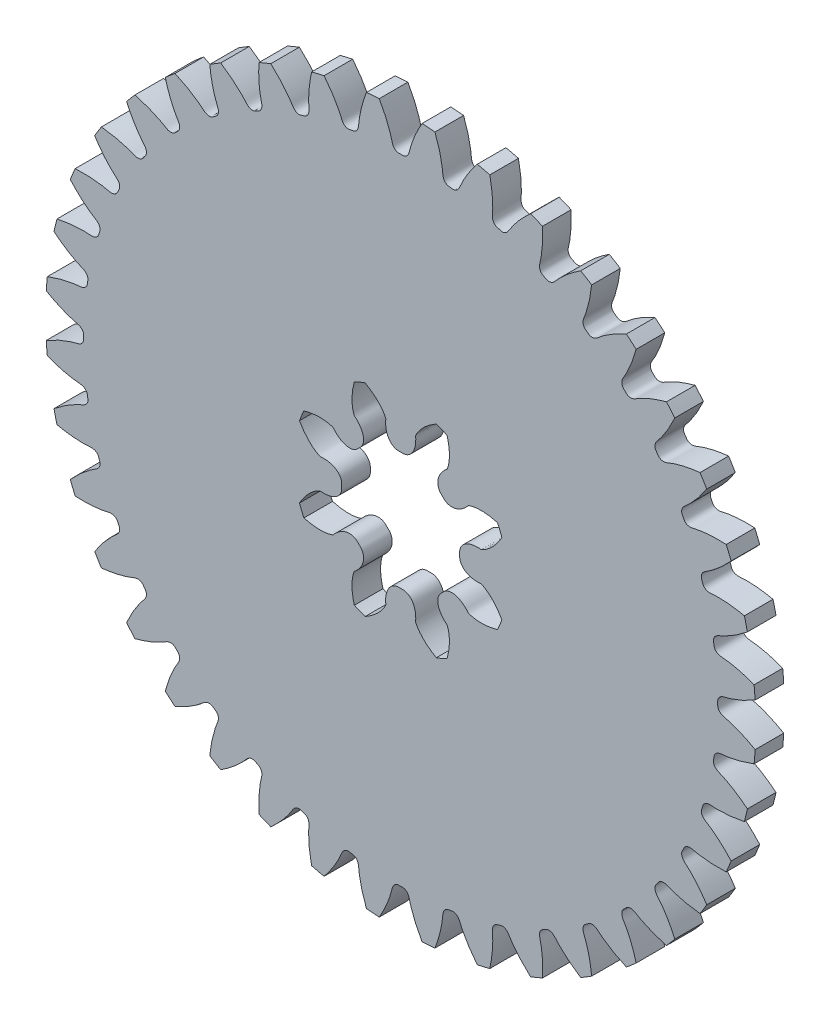
from build123d import *

# Parameters (mm, degrees)
SKETCHREVOLVESPUR03_W       = 0.250000008
SKETCHREVOLVESPUR03_H       = 3.102272727
TOOTHEXTRUDECUTSPUR03_DEPTH = 0.125000004
PATTERNSPUR03_COUNT         = 40
CORTAR_EXTRUIR1_REACH       = 2.25


with BuildPart() as part:
    # SketchRevolveSpur03 → Spur03 (revolve)
    with BuildSketch(Plane(origin=(0, 0, 0), x_dir=(0, 0, -1), z_dir=(1, 0, 0))):
        with Locations((0, 1.551136364)):
            Rectangle(SKETCHREVOLVESPUR03_W, SKETCHREVOLVESPUR03_H)
    revolve(axis=Axis((0, 0, 0), (0, 0, -1)))

    # SketchToothSpur03 → ToothExtrudeCutSpur03 (cut, symmetric)
    with BuildSketch(Plane.XY):
        with BuildLine():
            ThreePointArc((3.103756958, 0.191500414), (3.109659091, 0), (3.103756958, -0.191500414))
            add(Edge.make_bspline(
                [(3.103756958, -0.191500414), (3.089958571, -0.183437206), (3.069434937, -0.171909373), (3.042182547, -0.157559173), (3.022725887, -0.147750608), (3.003885393, -0.138667971), (2.985680448, -0.130286203), (2.968129739, -0.122579785), (2.951251244, -0.115522753), (2.935062223, -0.109088743), (2.919579222, -0.103250927), (2.904818003, -0.097982292), (2.890793757, -0.09325477), (2.877520332, -0.089042288), (2.865012831, -0.085310464), (2.853278786, -0.082051555), (2.840110694, -0.078576768), (2.829541976, -0.076303361), (2.821577551, -0.074080182), (2.81804308, -0.072981439), (2.814565605, -0.071785315), (2.811133562, -0.070477155), (2.807733196, -0.069039835), (2.804349374, -0.067450131), (2.800965801, -0.065677577), (2.797566051, -0.063682079), (2.794135555, -0.06141129), (2.790665342, -0.058797738), (2.787158476, -0.055756522), (2.783640387, -0.052185354), (2.780173538, -0.047970253), (2.77687517, -0.043002165), (2.773929219, -0.037209007), (2.7715863, -0.030604601), (2.770167189, -0.023647953), (2.76958925, -0.013359111), (2.770097963, 0), (2.76958925, 0.013359111), (2.770167189, 0.023647953), (2.7715863, 0.030604601), (2.773929219, 0.037209007), (2.77687517, 0.043002165), (2.780173538, 0.047970253), (2.783640387, 0.052185354), (2.787158476, 0.055756522), (2.790665342, 0.058797738), (2.794135555, 0.06141129), (2.797566051, 0.063682079), (2.800965801, 0.065677577), (2.804349374, 0.067450131), (2.807733196, 0.069039835), (2.811133562, 0.070477155), (2.814565605, 0.071785315), (2.81804308, 0.072981439), (2.821577551, 0.074080182), (2.829541976, 0.076303361), (2.840110694, 0.078576768), (2.853278786, 0.082051555), (2.865012831, 0.085310464), (2.877520332, 0.089042288), (2.890793757, 0.09325477), (2.904818003, 0.097982292), (2.919579222, 0.103250927), (2.935062223, 0.109088743), (2.951251244, 0.115522753), (2.968129739, 0.122579785), (2.985680448, 0.130286203), (3.003885393, 0.138667971), (3.022725887, 0.147750608), (3.042182547, 0.157559173), (3.069434937, 0.171909373), (3.089958571, 0.183437206), (3.103756958, 0.191500414)],
                knots=[0, 0, 0, 0, 0.058939817, 0.086798701, 0.113583569, 0.139294421, 0.163931256, 0.187494075, 0.209982877, 0.231397663, 0.251738433, 0.271005186, 0.289197923, 0.306316644, 0.322361348, 0.337332036, 0.351228708, 0.37258347, 0.377176766, 0.381719791, 0.386232054, 0.390736985, 0.395262836, 0.399843783, 0.404521226, 0.409345251, 0.414376113, 0.419685382, 0.425356036, 0.431480139, 0.438151913, 0.445453321, 0.453430002, 0.462059599, 0.471223406, 0.479505771, 0.5, 0.520494229, 0.528776594, 0.537940401, 0.546569998, 0.554546679, 0.561848087, 0.568519861, 0.574643964, 0.580314618, 0.585623887, 0.590654749, 0.595478774, 0.600156217, 0.604737164, 0.609263015, 0.613767946, 0.618280209, 0.622823234, 0.62741653, 0.648771292, 0.662667964, 0.677638652, 0.693683356, 0.710802077, 0.728994814, 0.748261567, 0.768602337, 0.790017123, 0.812505925, 0.836068744, 0.860705579, 0.886416431, 0.913201299, 0.941060183, 1, 1, 1, 1], degree=3))
        make_face()
    toothextrudecutspur03 = extrude(amount=TOOTHEXTRUDECUTSPUR03_DEPTH, both=True, mode=Mode.SUBTRACT)

    # PatternSpur03: ToothExtrudeCutSpur03 ×40 about axis
    patternspur03_axis = Axis((0, 0, 55), (0, 0, -1))
    for i in range(1, PATTERNSPUR03_COUNT):
        add(toothextrudecutspur03.rotate(patternspur03_axis, i * 360 / PATTERNSPUR03_COUNT), mode=Mode.SUBTRACT)

    # Croquis1 → Cortar-Extruir1 (cut, up to next)
    with BuildSketch(Plane.XY.offset(0.125000004), mode=Mode.PRIVATE) as cortar_extruir1_sk1:
        with BuildLine():
            ThreePointArc((0.884276826, 0.311385204), (0.866137062, 0.358765718), (0.845460729, 0.40509555))
            add(Edge.make_bspline(
                [(0.40509555, 0.845460729), (0.41104992, 0.82421079), (0.417581278, 0.795017734), (0.422660577, 0.758165224), (0.424683928, 0.736267056), (0.425657177, 0.715717392), (0.425705504, 0.696563518), (0.424955758, 0.678844441), (0.423537683, 0.662589442), (0.421577298, 0.647822948), (0.419216329, 0.63454842), (0.416547699, 0.622799977), (0.41381674, 0.612479723), (0.409996653, 0.601570817), (0.406537284, 0.587402055), (0.393839297, 0.580181147), (0.385745612, 0.571960162), (0.379502767, 0.565796374), (0.37365305, 0.559490513), (0.368090946, 0.553127716), (0.362844752, 0.546690764), (0.357908152, 0.540188436), (0.353284269, 0.53362198), (0.348974315, 0.526993814), (0.344980743, 0.520305215), (0.341306635, 0.513556897), (0.337956124, 0.506748868), (0.334934586, 0.499880513), (0.332248947, 0.492950674), (0.329908003, 0.485957822), (0.327922789, 0.47890031), (0.326306957, 0.471776771), (0.325077161, 0.464586672), (0.324253388, 0.457331077), (0.323859178, 0.450013663), (0.323921634, 0.442641992), (0.324471102, 0.435229056), (0.325540351, 0.427795002), (0.327163143, 0.42036895), (0.329371904, 0.41299049), (0.332195098, 0.405711082), (0.335652038, 0.398592737), (0.339754663, 0.391711891), (0.344482093, 0.385136545), (0.349178399, 0.379775699), (0.355871813, 0.372902772), (0.364763468, 0.364763468), (0.372902772, 0.355871813), (0.379775699, 0.349178399), (0.385136545, 0.344482093), (0.391711891, 0.339754663), (0.398592737, 0.335652038), (0.405711082, 0.332195098), (0.41299049, 0.329371904), (0.42036895, 0.327163143), (0.427795002, 0.325540351), (0.435229056, 0.324471102), (0.442641992, 0.323921634), (0.450013663, 0.323859178), (0.457331077, 0.324253388), (0.464586672, 0.325077161), (0.471776771, 0.326306957), (0.47890031, 0.327922789), (0.485957822, 0.329908003), (0.492950674, 0.332248947), (0.499880513, 0.334934586), (0.506748868, 0.337956124), (0.513556897, 0.341306635), (0.520305215, 0.344980743), (0.526993814, 0.348974315), (0.53362198, 0.353284269), (0.540188436, 0.357908152), (0.546690764, 0.362844752), (0.553127716, 0.368090946), (0.559490513, 0.37365305), (0.565796374, 0.379502767), (0.571960162, 0.385745612), (0.580181147, 0.393839297), (0.587402055, 0.406537284), (0.601570817, 0.409996653), (0.612479723, 0.41381674), (0.622799977, 0.416547699), (0.63454842, 0.419216329), (0.647822948, 0.421577298), (0.662589442, 0.423537683), (0.678844441, 0.424955758), (0.696563518, 0.425705504), (0.715717392, 0.425657177), (0.736267056, 0.424683928), (0.758165224, 0.422660577), (0.795017734, 0.417581278), (0.82421079, 0.41104992), (0.845460729, 0.40509555)],
                knots=[0.011652886, 0.011652886, 0.011652886, 0.011652886, 0.073215091, 0.094985485, 0.115436462, 0.13456802, 0.152380161, 0.168872885, 0.18404619, 0.197900078, 0.210434548, 0.2216496, 0.231545235, 0.240121452, 0.254210701, 0.270122213, 0.278421846, 0.286569565, 0.29456997, 0.302428107, 0.310149525, 0.317740329, 0.325207234, 0.332557632, 0.339799658, 0.346942256, 0.353995249, 0.360969402, 0.367876475, 0.374729261, 0.381541598, 0.388328329, 0.395105215, 0.40188875, 0.408695881, 0.415543575, 0.422448236, 0.429424941, 0.436486513, 0.443642464, 0.450897926, 0.458252678, 0.465700501, 0.473229037, 0.480820311, 0.485565802, 0.5, 0.514434198, 0.519179689, 0.526770963, 0.534299499, 0.541747322, 0.549102074, 0.556357536, 0.563513487, 0.570575059, 0.577551764, 0.584456425, 0.591304119, 0.59811125, 0.604894785, 0.611671671, 0.618458402, 0.625270739, 0.632123525, 0.639030598, 0.646004751, 0.653057744, 0.660200342, 0.667442368, 0.674792766, 0.682259671, 0.689850475, 0.697571893, 0.70543003, 0.713430435, 0.721578154, 0.729877787, 0.745789299, 0.759878548, 0.768454765, 0.7783504, 0.789565452, 0.802099922, 0.81595381, 0.831127115, 0.847619839, 0.86543198, 0.884563538, 0.905014515, 0.926784909, 0.988347114, 0.988347114, 0.988347114, 0.988347114], degree=3))
            ThreePointArc((0.40509555, 0.845460729), (0.358765718, 0.866137062), (0.311385204, 0.884276826))
            add(Edge.make_bspline(
                [(-0.311385204, 0.884276826), (-0.292148853, 0.873461225), (-0.266887878, 0.857436984), (-0.237237611, 0.834969931), (-0.220322543, 0.820916314), (-0.205103545, 0.807073697), (-0.191525539, 0.793564035), (-0.179526409, 0.780504605), (-0.169035119, 0.768007855), (-0.159979833, 0.756180166), (-0.152262782, 0.7451242), (-0.145842384, 0.73492979), (-0.140475942, 0.725701189), (-0.13546339, 0.715286218), (-0.127890706, 0.702821246), (-0.131763586, 0.688736461), (-0.131673571, 0.677200247), (-0.131729473, 0.668427432), (-0.131406931, 0.659832141), (-0.130840755, 0.651399963), (-0.129998762, 0.643138731), (-0.128891624, 0.635050187), (-0.127518019, 0.627137423), (-0.125878795, 0.619403004), (-0.123973123, 0.611849568), (-0.121799328, 0.6044798), (-0.119354494, 0.597296628), (-0.116634383, 0.590303417), (-0.113633281, 0.583504248), (-0.110343885, 0.576904257), (-0.106757229, 0.570510084), (-0.102862692, 0.564330416), (-0.098648121, 0.558376651), (-0.094100136, 0.552663676), (-0.089204692, 0.547210734), (-0.08394797, 0.542042338), (-0.0783177, 0.537189134), (-0.072304957, 0.532688537), (-0.065906458, 0.528585012), (-0.059127269, 0.524929483), (-0.051983651, 0.521778464), (-0.044505795, 0.51918946), (-0.036739308, 0.517224961), (-0.028747039, 0.515918287), (-0.021635558, 0.515448385), (-0.012042707, 0.515321452), (0, 0.515853444), (0.012042707, 0.515321452), (0.021635558, 0.515448385), (0.028747039, 0.515918287), (0.036739308, 0.517224961), (0.044505795, 0.51918946), (0.051983651, 0.521778464), (0.059127269, 0.524929483), (0.065906458, 0.528585012), (0.072304957, 0.532688537), (0.0783177, 0.537189134), (0.08394797, 0.542042338), (0.089204692, 0.547210734), (0.094100136, 0.552663676), (0.098648121, 0.558376651), (0.102862692, 0.564330416), (0.106757229, 0.570510084), (0.110343885, 0.576904257), (0.113633281, 0.583504248), (0.116634383, 0.590303417), (0.119354494, 0.597296628), (0.121799328, 0.6044798), (0.123973123, 0.611849568), (0.125878795, 0.619403004), (0.127518019, 0.627137423), (0.128891624, 0.635050187), (0.129998762, 0.643138731), (0.130840755, 0.651399963), (0.131406931, 0.659832141), (0.131729473, 0.668427432), (0.131673571, 0.677200247), (0.131763586, 0.688736461), (0.127890706, 0.702821246), (0.13546339, 0.715286218), (0.140475942, 0.725701189), (0.145842384, 0.73492979), (0.152262782, 0.7451242), (0.159979833, 0.756180166), (0.169035119, 0.768007855), (0.179526409, 0.780504605), (0.191525539, 0.793564035), (0.205103545, 0.807073697), (0.220322543, 0.820916314), (0.237237611, 0.834969931), (0.266887878, 0.857436984), (0.292148853, 0.873461225), (0.311385204, 0.884276826)],
                knots=[0.011652886, 0.011652886, 0.011652886, 0.011652886, 0.073215091, 0.094985485, 0.115436462, 0.13456802, 0.152380161, 0.168872885, 0.18404619, 0.197900078, 0.210434548, 0.2216496, 0.231545235, 0.240121452, 0.254210701, 0.270122213, 0.278421846, 0.286569565, 0.29456997, 0.302428107, 0.310149525, 0.317740329, 0.325207234, 0.332557632, 0.339799658, 0.346942256, 0.353995249, 0.360969402, 0.367876475, 0.374729261, 0.381541598, 0.388328329, 0.395105215, 0.40188875, 0.408695881, 0.415543575, 0.422448236, 0.429424941, 0.436486513, 0.443642464, 0.450897926, 0.458252678, 0.465700501, 0.473229037, 0.480820311, 0.485565802, 0.5, 0.514434198, 0.519179689, 0.526770963, 0.534299499, 0.541747322, 0.549102074, 0.556357536, 0.563513487, 0.570575059, 0.577551764, 0.584456425, 0.591304119, 0.59811125, 0.604894785, 0.611671671, 0.618458402, 0.625270739, 0.632123525, 0.639030598, 0.646004751, 0.653057744, 0.660200342, 0.667442368, 0.674792766, 0.682259671, 0.689850475, 0.697571893, 0.70543003, 0.713430435, 0.721578154, 0.729877787, 0.745789299, 0.759878548, 0.768454765, 0.7783504, 0.789565452, 0.802099922, 0.81595381, 0.831127115, 0.847619839, 0.86543198, 0.884563538, 0.905014515, 0.926784909, 0.988347114, 0.988347114, 0.988347114, 0.988347114], degree=3))
            ThreePointArc((-0.311385204, 0.884276826), (-0.358765718, 0.866137062), (-0.40509555, 0.845460729))
            add(Edge.make_bspline(
                [(-0.845460729, 0.40509555), (-0.82421079, 0.41104992), (-0.795017734, 0.417581278), (-0.758165224, 0.422660577), (-0.736267056, 0.424683928), (-0.715717392, 0.425657177), (-0.696563518, 0.425705504), (-0.678844441, 0.424955758), (-0.662589442, 0.423537683), (-0.647822948, 0.421577298), (-0.63454842, 0.419216329), (-0.622799977, 0.416547699), (-0.612479723, 0.41381674), (-0.601570817, 0.409996653), (-0.587402055, 0.406537284), (-0.580181147, 0.393839297), (-0.571960162, 0.385745612), (-0.565796374, 0.379502767), (-0.559490513, 0.37365305), (-0.553127716, 0.368090946), (-0.546690764, 0.362844752), (-0.540188436, 0.357908152), (-0.53362198, 0.353284269), (-0.526993814, 0.348974315), (-0.520305215, 0.344980743), (-0.513556897, 0.341306635), (-0.506748868, 0.337956124), (-0.499880513, 0.334934586), (-0.492950674, 0.332248947), (-0.485957822, 0.329908003), (-0.47890031, 0.327922789), (-0.471776771, 0.326306957), (-0.464586672, 0.325077161), (-0.457331077, 0.324253388), (-0.450013663, 0.323859178), (-0.442641992, 0.323921634), (-0.435229056, 0.324471102), (-0.427795002, 0.325540351), (-0.42036895, 0.327163143), (-0.41299049, 0.329371904), (-0.405711082, 0.332195098), (-0.398592737, 0.335652038), (-0.391711891, 0.339754663), (-0.385136545, 0.344482093), (-0.379775699, 0.349178399), (-0.372902772, 0.355871813), (-0.364763468, 0.364763468), (-0.355871813, 0.372902772), (-0.349178399, 0.379775699), (-0.344482093, 0.385136545), (-0.339754663, 0.391711891), (-0.335652038, 0.398592737), (-0.332195098, 0.405711082), (-0.329371904, 0.41299049), (-0.327163143, 0.42036895), (-0.325540351, 0.427795002), (-0.324471102, 0.435229056), (-0.323921634, 0.442641992), (-0.323859178, 0.450013663), (-0.324253388, 0.457331077), (-0.325077161, 0.464586672), (-0.326306957, 0.471776771), (-0.327922789, 0.47890031), (-0.329908003, 0.485957822), (-0.332248947, 0.492950674), (-0.334934586, 0.499880513), (-0.337956124, 0.506748868), (-0.341306635, 0.513556897), (-0.344980743, 0.520305215), (-0.348974315, 0.526993814), (-0.353284269, 0.53362198), (-0.357908152, 0.540188436), (-0.362844752, 0.546690764), (-0.368090946, 0.553127716), (-0.37365305, 0.559490513), (-0.379502767, 0.565796374), (-0.385745612, 0.571960162), (-0.393839297, 0.580181147), (-0.406537284, 0.587402055), (-0.409996653, 0.601570817), (-0.41381674, 0.612479723), (-0.416547699, 0.622799977), (-0.419216329, 0.63454842), (-0.421577298, 0.647822948), (-0.423537683, 0.662589442), (-0.424955758, 0.678844441), (-0.425705504, 0.696563518), (-0.425657177, 0.715717392), (-0.424683928, 0.736267056), (-0.422660577, 0.758165224), (-0.417581278, 0.795017734), (-0.41104992, 0.82421079), (-0.40509555, 0.845460729)],
                knots=[0.011652886, 0.011652886, 0.011652886, 0.011652886, 0.073215091, 0.094985485, 0.115436462, 0.13456802, 0.152380161, 0.168872885, 0.18404619, 0.197900078, 0.210434548, 0.2216496, 0.231545235, 0.240121452, 0.254210701, 0.270122213, 0.278421846, 0.286569565, 0.29456997, 0.302428107, 0.310149525, 0.317740329, 0.325207234, 0.332557632, 0.339799658, 0.346942256, 0.353995249, 0.360969402, 0.367876475, 0.374729261, 0.381541598, 0.388328329, 0.395105215, 0.40188875, 0.408695881, 0.415543575, 0.422448236, 0.429424941, 0.436486513, 0.443642464, 0.450897926, 0.458252678, 0.465700501, 0.473229037, 0.480820311, 0.485565802, 0.5, 0.514434198, 0.519179689, 0.526770963, 0.534299499, 0.541747322, 0.549102074, 0.556357536, 0.563513487, 0.570575059, 0.577551764, 0.584456425, 0.591304119, 0.59811125, 0.604894785, 0.611671671, 0.618458402, 0.625270739, 0.632123525, 0.639030598, 0.646004751, 0.653057744, 0.660200342, 0.667442368, 0.674792766, 0.682259671, 0.689850475, 0.697571893, 0.70543003, 0.713430435, 0.721578154, 0.729877787, 0.745789299, 0.759878548, 0.768454765, 0.7783504, 0.789565452, 0.802099922, 0.81595381, 0.831127115, 0.847619839, 0.86543198, 0.884563538, 0.905014515, 0.926784909, 0.988347114, 0.988347114, 0.988347114, 0.988347114], degree=3))
            ThreePointArc((-0.845460729, 0.40509555), (-0.866137062, 0.358765718), (-0.884276826, 0.311385204))
            add(Edge.make_bspline(
                [(-0.884276826, -0.311385204), (-0.873461225, -0.292148853), (-0.857436984, -0.266887878), (-0.834969931, -0.237237611), (-0.820916314, -0.220322543), (-0.807073697, -0.205103545), (-0.793564035, -0.191525539), (-0.780504605, -0.179526409), (-0.768007855, -0.169035119), (-0.756180166, -0.159979833), (-0.7451242, -0.152262782), (-0.73492979, -0.145842384), (-0.725701189, -0.140475942), (-0.715286218, -0.13546339), (-0.702821246, -0.127890706), (-0.688736461, -0.131763586), (-0.677200247, -0.131673571), (-0.668427432, -0.131729473), (-0.659832141, -0.131406931), (-0.651399963, -0.130840755), (-0.643138731, -0.129998762), (-0.635050187, -0.128891624), (-0.627137423, -0.127518019), (-0.619403004, -0.125878795), (-0.611849568, -0.123973123), (-0.6044798, -0.121799328), (-0.597296628, -0.119354494), (-0.590303417, -0.116634383), (-0.583504248, -0.113633281), (-0.576904257, -0.110343885), (-0.570510084, -0.106757229), (-0.564330416, -0.102862692), (-0.558376651, -0.098648121), (-0.552663676, -0.094100136), (-0.547210734, -0.089204692), (-0.542042338, -0.08394797), (-0.537189134, -0.0783177), (-0.532688537, -0.072304957), (-0.528585012, -0.065906458), (-0.524929483, -0.059127269), (-0.521778464, -0.051983651), (-0.51918946, -0.044505795), (-0.517224961, -0.036739308), (-0.515918287, -0.028747039), (-0.515448385, -0.021635558), (-0.515321452, -0.012042707), (-0.515853444, 0), (-0.515321452, 0.012042707), (-0.515448385, 0.021635558), (-0.515918287, 0.028747039), (-0.517224961, 0.036739308), (-0.51918946, 0.044505795), (-0.521778464, 0.051983651), (-0.524929483, 0.059127269), (-0.528585012, 0.065906458), (-0.532688537, 0.072304957), (-0.537189134, 0.0783177), (-0.542042338, 0.08394797), (-0.547210734, 0.089204692), (-0.552663676, 0.094100136), (-0.558376651, 0.098648121), (-0.564330416, 0.102862692), (-0.570510084, 0.106757229), (-0.576904257, 0.110343885), (-0.583504248, 0.113633281), (-0.590303417, 0.116634383), (-0.597296628, 0.119354494), (-0.6044798, 0.121799328), (-0.611849568, 0.123973123), (-0.619403004, 0.125878795), (-0.627137423, 0.127518019), (-0.635050187, 0.128891624), (-0.643138731, 0.129998762), (-0.651399963, 0.130840755), (-0.659832141, 0.131406931), (-0.668427432, 0.131729473), (-0.677200247, 0.131673571), (-0.688736461, 0.131763586), (-0.702821246, 0.127890706), (-0.715286218, 0.13546339), (-0.725701189, 0.140475942), (-0.73492979, 0.145842384), (-0.7451242, 0.152262782), (-0.756180166, 0.159979833), (-0.768007855, 0.169035119), (-0.780504605, 0.179526409), (-0.793564035, 0.191525539), (-0.807073697, 0.205103545), (-0.820916314, 0.220322543), (-0.834969931, 0.237237611), (-0.857436984, 0.266887878), (-0.873461225, 0.292148853), (-0.884276826, 0.311385204)],
                knots=[0.011652886, 0.011652886, 0.011652886, 0.011652886, 0.073215091, 0.094985485, 0.115436462, 0.13456802, 0.152380161, 0.168872885, 0.18404619, 0.197900078, 0.210434548, 0.2216496, 0.231545235, 0.240121452, 0.254210701, 0.270122213, 0.278421846, 0.286569565, 0.29456997, 0.302428107, 0.310149525, 0.317740329, 0.325207234, 0.332557632, 0.339799658, 0.346942256, 0.353995249, 0.360969402, 0.367876475, 0.374729261, 0.381541598, 0.388328329, 0.395105215, 0.40188875, 0.408695881, 0.415543575, 0.422448236, 0.429424941, 0.436486513, 0.443642464, 0.450897926, 0.458252678, 0.465700501, 0.473229037, 0.480820311, 0.485565802, 0.5, 0.514434198, 0.519179689, 0.526770963, 0.534299499, 0.541747322, 0.549102074, 0.556357536, 0.563513487, 0.570575059, 0.577551764, 0.584456425, 0.591304119, 0.59811125, 0.604894785, 0.611671671, 0.618458402, 0.625270739, 0.632123525, 0.639030598, 0.646004751, 0.653057744, 0.660200342, 0.667442368, 0.674792766, 0.682259671, 0.689850475, 0.697571893, 0.70543003, 0.713430435, 0.721578154, 0.729877787, 0.745789299, 0.759878548, 0.768454765, 0.7783504, 0.789565452, 0.802099922, 0.81595381, 0.831127115, 0.847619839, 0.86543198, 0.884563538, 0.905014515, 0.926784909, 0.988347114, 0.988347114, 0.988347114, 0.988347114], degree=3))
            ThreePointArc((-0.884276826, -0.311385204), (-0.866137062, -0.358765718), (-0.845460729, -0.40509555))
            add(Edge.make_bspline(
                [(-0.40509555, -0.845460729), (-0.41104992, -0.82421079), (-0.417581278, -0.795017734), (-0.422660577, -0.758165224), (-0.424683928, -0.736267056), (-0.425657177, -0.715717392), (-0.425705504, -0.696563518), (-0.424955758, -0.678844441), (-0.423537683, -0.662589442), (-0.421577298, -0.647822948), (-0.419216329, -0.63454842), (-0.416547699, -0.622799977), (-0.41381674, -0.612479723), (-0.409996653, -0.601570817), (-0.406537284, -0.587402055), (-0.393839297, -0.580181147), (-0.385745612, -0.571960162), (-0.379502767, -0.565796374), (-0.37365305, -0.559490513), (-0.368090946, -0.553127716), (-0.362844752, -0.546690764), (-0.357908152, -0.540188436), (-0.353284269, -0.53362198), (-0.348974315, -0.526993814), (-0.344980743, -0.520305215), (-0.341306635, -0.513556897), (-0.337956124, -0.506748868), (-0.334934586, -0.499880513), (-0.332248947, -0.492950674), (-0.329908003, -0.485957822), (-0.327922789, -0.47890031), (-0.326306957, -0.471776771), (-0.325077161, -0.464586672), (-0.324253388, -0.457331077), (-0.323859178, -0.450013663), (-0.323921634, -0.442641992), (-0.324471102, -0.435229056), (-0.325540351, -0.427795002), (-0.327163143, -0.42036895), (-0.329371904, -0.41299049), (-0.332195098, -0.405711082), (-0.335652038, -0.398592737), (-0.339754663, -0.391711891), (-0.344482093, -0.385136545), (-0.349178399, -0.379775699), (-0.355871813, -0.372902772), (-0.364763468, -0.364763468), (-0.372902772, -0.355871813), (-0.379775699, -0.349178399), (-0.385136545, -0.344482093), (-0.391711891, -0.339754663), (-0.398592737, -0.335652038), (-0.405711082, -0.332195098), (-0.41299049, -0.329371904), (-0.42036895, -0.327163143), (-0.427795002, -0.325540351), (-0.435229056, -0.324471102), (-0.442641992, -0.323921634), (-0.450013663, -0.323859178), (-0.457331077, -0.324253388), (-0.464586672, -0.325077161), (-0.471776771, -0.326306957), (-0.47890031, -0.327922789), (-0.485957822, -0.329908003), (-0.492950674, -0.332248947), (-0.499880513, -0.334934586), (-0.506748868, -0.337956124), (-0.513556897, -0.341306635), (-0.520305215, -0.344980743), (-0.526993814, -0.348974315), (-0.53362198, -0.353284269), (-0.540188436, -0.357908152), (-0.546690764, -0.362844752), (-0.553127716, -0.368090946), (-0.559490513, -0.37365305), (-0.565796374, -0.379502767), (-0.571960162, -0.385745612), (-0.580181147, -0.393839297), (-0.587402055, -0.406537284), (-0.601570817, -0.409996653), (-0.612479723, -0.41381674), (-0.622799977, -0.416547699), (-0.63454842, -0.419216329), (-0.647822948, -0.421577298), (-0.662589442, -0.423537683), (-0.678844441, -0.424955758), (-0.696563518, -0.425705504), (-0.715717392, -0.425657177), (-0.736267056, -0.424683928), (-0.758165224, -0.422660577), (-0.795017734, -0.417581278), (-0.82421079, -0.41104992), (-0.845460729, -0.40509555)],
                knots=[0.011652886, 0.011652886, 0.011652886, 0.011652886, 0.073215091, 0.094985485, 0.115436462, 0.13456802, 0.152380161, 0.168872885, 0.18404619, 0.197900078, 0.210434548, 0.2216496, 0.231545235, 0.240121452, 0.254210701, 0.270122213, 0.278421846, 0.286569565, 0.29456997, 0.302428107, 0.310149525, 0.317740329, 0.325207234, 0.332557632, 0.339799658, 0.346942256, 0.353995249, 0.360969402, 0.367876475, 0.374729261, 0.381541598, 0.388328329, 0.395105215, 0.40188875, 0.408695881, 0.415543575, 0.422448236, 0.429424941, 0.436486513, 0.443642464, 0.450897926, 0.458252678, 0.465700501, 0.473229037, 0.480820311, 0.485565802, 0.5, 0.514434198, 0.519179689, 0.526770963, 0.534299499, 0.541747322, 0.549102074, 0.556357536, 0.563513487, 0.570575059, 0.577551764, 0.584456425, 0.591304119, 0.59811125, 0.604894785, 0.611671671, 0.618458402, 0.625270739, 0.632123525, 0.639030598, 0.646004751, 0.653057744, 0.660200342, 0.667442368, 0.674792766, 0.682259671, 0.689850475, 0.697571893, 0.70543003, 0.713430435, 0.721578154, 0.729877787, 0.745789299, 0.759878548, 0.768454765, 0.7783504, 0.789565452, 0.802099922, 0.81595381, 0.831127115, 0.847619839, 0.86543198, 0.884563538, 0.905014515, 0.926784909, 0.988347114, 0.988347114, 0.988347114, 0.988347114], degree=3))
            ThreePointArc((-0.40509555, -0.845460729), (-0.358765718, -0.866137062), (-0.311385204, -0.884276826))
            add(Edge.make_bspline(
                [(0.311385204, -0.884276826), (0.292148853, -0.873461225), (0.266887878, -0.857436984), (0.237237611, -0.834969931), (0.220322543, -0.820916314), (0.205103545, -0.807073697), (0.191525539, -0.793564035), (0.179526409, -0.780504605), (0.169035119, -0.768007855), (0.159979833, -0.756180166), (0.152262782, -0.7451242), (0.145842384, -0.73492979), (0.140475942, -0.725701189), (0.13546339, -0.715286218), (0.127890706, -0.702821246), (0.131763586, -0.688736461), (0.131673571, -0.677200247), (0.131729473, -0.668427432), (0.131406931, -0.659832141), (0.130840755, -0.651399963), (0.129998762, -0.643138731), (0.128891624, -0.635050187), (0.127518019, -0.627137423), (0.125878795, -0.619403004), (0.123973123, -0.611849568), (0.121799328, -0.6044798), (0.119354494, -0.597296628), (0.116634383, -0.590303417), (0.113633281, -0.583504248), (0.110343885, -0.576904257), (0.106757229, -0.570510084), (0.102862692, -0.564330416), (0.098648121, -0.558376651), (0.094100136, -0.552663676), (0.089204692, -0.547210734), (0.08394797, -0.542042338), (0.0783177, -0.537189134), (0.072304957, -0.532688537), (0.065906458, -0.528585012), (0.059127269, -0.524929483), (0.051983651, -0.521778464), (0.044505795, -0.51918946), (0.036739308, -0.517224961), (0.028747039, -0.515918287), (0.021635558, -0.515448385), (0.012042707, -0.515321452), (0, -0.515853444), (-0.012042707, -0.515321452), (-0.021635558, -0.515448385), (-0.028747039, -0.515918287), (-0.036739308, -0.517224961), (-0.044505795, -0.51918946), (-0.051983651, -0.521778464), (-0.059127269, -0.524929483), (-0.065906458, -0.528585012), (-0.072304957, -0.532688537), (-0.0783177, -0.537189134), (-0.08394797, -0.542042338), (-0.089204692, -0.547210734), (-0.094100136, -0.552663676), (-0.098648121, -0.558376651), (-0.102862692, -0.564330416), (-0.106757229, -0.570510084), (-0.110343885, -0.576904257), (-0.113633281, -0.583504248), (-0.116634383, -0.590303417), (-0.119354494, -0.597296628), (-0.121799328, -0.6044798), (-0.123973123, -0.611849568), (-0.125878795, -0.619403004), (-0.127518019, -0.627137423), (-0.128891624, -0.635050187), (-0.129998762, -0.643138731), (-0.130840755, -0.651399963), (-0.131406931, -0.659832141), (-0.131729473, -0.668427432), (-0.131673571, -0.677200247), (-0.131763586, -0.688736461), (-0.127890706, -0.702821246), (-0.13546339, -0.715286218), (-0.140475942, -0.725701189), (-0.145842384, -0.73492979), (-0.152262782, -0.7451242), (-0.159979833, -0.756180166), (-0.169035119, -0.768007855), (-0.179526409, -0.780504605), (-0.191525539, -0.793564035), (-0.205103545, -0.807073697), (-0.220322543, -0.820916314), (-0.237237611, -0.834969931), (-0.266887878, -0.857436984), (-0.292148853, -0.873461225), (-0.311385204, -0.884276826)],
                knots=[0.011652886, 0.011652886, 0.011652886, 0.011652886, 0.073215091, 0.094985485, 0.115436462, 0.13456802, 0.152380161, 0.168872885, 0.18404619, 0.197900078, 0.210434548, 0.2216496, 0.231545235, 0.240121452, 0.254210701, 0.270122213, 0.278421846, 0.286569565, 0.29456997, 0.302428107, 0.310149525, 0.317740329, 0.325207234, 0.332557632, 0.339799658, 0.346942256, 0.353995249, 0.360969402, 0.367876475, 0.374729261, 0.381541598, 0.388328329, 0.395105215, 0.40188875, 0.408695881, 0.415543575, 0.422448236, 0.429424941, 0.436486513, 0.443642464, 0.450897926, 0.458252678, 0.465700501, 0.473229037, 0.480820311, 0.485565802, 0.5, 0.514434198, 0.519179689, 0.526770963, 0.534299499, 0.541747322, 0.549102074, 0.556357536, 0.563513487, 0.570575059, 0.577551764, 0.584456425, 0.591304119, 0.59811125, 0.604894785, 0.611671671, 0.618458402, 0.625270739, 0.632123525, 0.639030598, 0.646004751, 0.653057744, 0.660200342, 0.667442368, 0.674792766, 0.682259671, 0.689850475, 0.697571893, 0.70543003, 0.713430435, 0.721578154, 0.729877787, 0.745789299, 0.759878548, 0.768454765, 0.7783504, 0.789565452, 0.802099922, 0.81595381, 0.831127115, 0.847619839, 0.86543198, 0.884563538, 0.905014515, 0.926784909, 0.988347114, 0.988347114, 0.988347114, 0.988347114], degree=3))
            ThreePointArc((0.311385204, -0.884276826), (0.358765718, -0.866137062), (0.40509555, -0.845460729))
            add(Edge.make_bspline(
                [(0.845460729, -0.40509555), (0.82421079, -0.41104992), (0.795017734, -0.417581278), (0.758165224, -0.422660577), (0.736267056, -0.424683928), (0.715717392, -0.425657177), (0.696563518, -0.425705504), (0.678844441, -0.424955758), (0.662589442, -0.423537683), (0.647822948, -0.421577298), (0.63454842, -0.419216329), (0.622799977, -0.416547699), (0.612479723, -0.41381674), (0.601570817, -0.409996653), (0.587402055, -0.406537284), (0.580181147, -0.393839297), (0.571960162, -0.385745612), (0.565796374, -0.379502767), (0.559490513, -0.37365305), (0.553127716, -0.368090946), (0.546690764, -0.362844752), (0.540188436, -0.357908152), (0.53362198, -0.353284269), (0.526993814, -0.348974315), (0.520305215, -0.344980743), (0.513556897, -0.341306635), (0.506748868, -0.337956124), (0.499880513, -0.334934586), (0.492950674, -0.332248947), (0.485957822, -0.329908003), (0.47890031, -0.327922789), (0.471776771, -0.326306957), (0.464586672, -0.325077161), (0.457331077, -0.324253388), (0.450013663, -0.323859178), (0.442641992, -0.323921634), (0.435229056, -0.324471102), (0.427795002, -0.325540351), (0.42036895, -0.327163143), (0.41299049, -0.329371904), (0.405711082, -0.332195098), (0.398592737, -0.335652038), (0.391711891, -0.339754663), (0.385136545, -0.344482093), (0.379775699, -0.349178399), (0.372902772, -0.355871813), (0.364763468, -0.364763468), (0.355871813, -0.372902772), (0.349178399, -0.379775699), (0.344482093, -0.385136545), (0.339754663, -0.391711891), (0.335652038, -0.398592737), (0.332195098, -0.405711082), (0.329371904, -0.41299049), (0.327163143, -0.42036895), (0.325540351, -0.427795002), (0.324471102, -0.435229056), (0.323921634, -0.442641992), (0.323859178, -0.450013663), (0.324253388, -0.457331077), (0.325077161, -0.464586672), (0.326306957, -0.471776771), (0.327922789, -0.47890031), (0.329908003, -0.485957822), (0.332248947, -0.492950674), (0.334934586, -0.499880513), (0.337956124, -0.506748868), (0.341306635, -0.513556897), (0.344980743, -0.520305215), (0.348974315, -0.526993814), (0.353284269, -0.53362198), (0.357908152, -0.540188436), (0.362844752, -0.546690764), (0.368090946, -0.553127716), (0.37365305, -0.559490513), (0.379502767, -0.565796374), (0.385745612, -0.571960162), (0.393839297, -0.580181147), (0.406537284, -0.587402055), (0.409996653, -0.601570817), (0.41381674, -0.612479723), (0.416547699, -0.622799977), (0.419216329, -0.63454842), (0.421577298, -0.647822948), (0.423537683, -0.662589442), (0.424955758, -0.678844441), (0.425705504, -0.696563518), (0.425657177, -0.715717392), (0.424683928, -0.736267056), (0.422660577, -0.758165224), (0.417581278, -0.795017734), (0.41104992, -0.82421079), (0.40509555, -0.845460729)],
                knots=[0.011652886, 0.011652886, 0.011652886, 0.011652886, 0.073215091, 0.094985485, 0.115436462, 0.13456802, 0.152380161, 0.168872885, 0.18404619, 0.197900078, 0.210434548, 0.2216496, 0.231545235, 0.240121452, 0.254210701, 0.270122213, 0.278421846, 0.286569565, 0.29456997, 0.302428107, 0.310149525, 0.317740329, 0.325207234, 0.332557632, 0.339799658, 0.346942256, 0.353995249, 0.360969402, 0.367876475, 0.374729261, 0.381541598, 0.388328329, 0.395105215, 0.40188875, 0.408695881, 0.415543575, 0.422448236, 0.429424941, 0.436486513, 0.443642464, 0.450897926, 0.458252678, 0.465700501, 0.473229037, 0.480820311, 0.485565802, 0.5, 0.514434198, 0.519179689, 0.526770963, 0.534299499, 0.541747322, 0.549102074, 0.556357536, 0.563513487, 0.570575059, 0.577551764, 0.584456425, 0.591304119, 0.59811125, 0.604894785, 0.611671671, 0.618458402, 0.625270739, 0.632123525, 0.639030598, 0.646004751, 0.653057744, 0.660200342, 0.667442368, 0.674792766, 0.682259671, 0.689850475, 0.697571893, 0.70543003, 0.713430435, 0.721578154, 0.729877787, 0.745789299, 0.759878548, 0.768454765, 0.7783504, 0.789565452, 0.802099922, 0.81595381, 0.831127115, 0.847619839, 0.86543198, 0.884563538, 0.905014515, 0.926784909, 0.988347114, 0.988347114, 0.988347114, 0.988347114], degree=3))
            ThreePointArc((0.845460729, -0.40509555), (0.866137062, -0.358765718), (0.884276826, -0.311385204))
            add(Edge.make_bspline(
                [(0.884276826, 0.311385204), (0.873461225, 0.292148853), (0.857436984, 0.266887878), (0.834969931, 0.237237611), (0.820916314, 0.220322543), (0.807073697, 0.205103545), (0.793564035, 0.191525539), (0.780504605, 0.179526409), (0.768007855, 0.169035119), (0.756180166, 0.159979833), (0.7451242, 0.152262782), (0.73492979, 0.145842384), (0.725701189, 0.140475942), (0.715286218, 0.13546339), (0.702821246, 0.127890706), (0.688736461, 0.131763586), (0.677200247, 0.131673571), (0.668427432, 0.131729473), (0.659832141, 0.131406931), (0.651399963, 0.130840755), (0.643138731, 0.129998762), (0.635050187, 0.128891624), (0.627137423, 0.127518019), (0.619403004, 0.125878795), (0.611849568, 0.123973123), (0.6044798, 0.121799328), (0.597296628, 0.119354494), (0.590303417, 0.116634383), (0.583504248, 0.113633281), (0.576904257, 0.110343885), (0.570510084, 0.106757229), (0.564330416, 0.102862692), (0.558376651, 0.098648121), (0.552663676, 0.094100136), (0.547210734, 0.089204692), (0.542042338, 0.08394797), (0.537189134, 0.0783177), (0.532688537, 0.072304957), (0.528585012, 0.065906458), (0.524929483, 0.059127269), (0.521778464, 0.051983651), (0.51918946, 0.044505795), (0.517224961, 0.036739308), (0.515918287, 0.028747039), (0.515448385, 0.021635558), (0.515321452, 0.012042707), (0.515853444, 0), (0.515321452, -0.012042707), (0.515448385, -0.021635558), (0.515918287, -0.028747039), (0.517224961, -0.036739308), (0.51918946, -0.044505795), (0.521778464, -0.051983651), (0.524929483, -0.059127269), (0.528585012, -0.065906458), (0.532688537, -0.072304957), (0.537189134, -0.0783177), (0.542042338, -0.08394797), (0.547210734, -0.089204692), (0.552663676, -0.094100136), (0.558376651, -0.098648121), (0.564330416, -0.102862692), (0.570510084, -0.106757229), (0.576904257, -0.110343885), (0.583504248, -0.113633281), (0.590303417, -0.116634383), (0.597296628, -0.119354494), (0.6044798, -0.121799328), (0.611849568, -0.123973123), (0.619403004, -0.125878795), (0.627137423, -0.127518019), (0.635050187, -0.128891624), (0.643138731, -0.129998762), (0.651399963, -0.130840755), (0.659832141, -0.131406931), (0.668427432, -0.131729473), (0.677200247, -0.131673571), (0.688736461, -0.131763586), (0.702821246, -0.127890706), (0.715286218, -0.13546339), (0.725701189, -0.140475942), (0.73492979, -0.145842384), (0.7451242, -0.152262782), (0.756180166, -0.159979833), (0.768007855, -0.169035119), (0.780504605, -0.179526409), (0.793564035, -0.191525539), (0.807073697, -0.205103545), (0.820916314, -0.220322543), (0.834969931, -0.237237611), (0.857436984, -0.266887878), (0.873461225, -0.292148853), (0.884276826, -0.311385204)],
                knots=[0.011652886, 0.011652886, 0.011652886, 0.011652886, 0.073215091, 0.094985485, 0.115436462, 0.13456802, 0.152380161, 0.168872885, 0.18404619, 0.197900078, 0.210434548, 0.2216496, 0.231545235, 0.240121452, 0.254210701, 0.270122213, 0.278421846, 0.286569565, 0.29456997, 0.302428107, 0.310149525, 0.317740329, 0.325207234, 0.332557632, 0.339799658, 0.346942256, 0.353995249, 0.360969402, 0.367876475, 0.374729261, 0.381541598, 0.388328329, 0.395105215, 0.40188875, 0.408695881, 0.415543575, 0.422448236, 0.429424941, 0.436486513, 0.443642464, 0.450897926, 0.458252678, 0.465700501, 0.473229037, 0.480820311, 0.485565802, 0.5, 0.514434198, 0.519179689, 0.526770963, 0.534299499, 0.541747322, 0.549102074, 0.556357536, 0.563513487, 0.570575059, 0.577551764, 0.584456425, 0.591304119, 0.59811125, 0.604894785, 0.611671671, 0.618458402, 0.625270739, 0.632123525, 0.639030598, 0.646004751, 0.653057744, 0.660200342, 0.667442368, 0.674792766, 0.682259671, 0.689850475, 0.697571893, 0.70543003, 0.713430435, 0.721578154, 0.729877787, 0.745789299, 0.759878548, 0.768454765, 0.7783504, 0.789565452, 0.802099922, 0.81595381, 0.831127115, 0.847619839, 0.86543198, 0.884563538, 0.905014515, 0.926784909, 0.988347114, 0.988347114, 0.988347114, 0.988347114], degree=3))
        make_face()
    cortar_extruir1_tool1 = extrude(cortar_extruir1_sk1.sketch, amount=-CORTAR_EXTRUIR1_REACH, mode=Mode.PRIVATE) & part.part
    add(cortar_extruir1_tool1.solids().sort_by_distance((0, 0, 0.125))[0], mode=Mode.SUBTRACT)


solid = part.part
